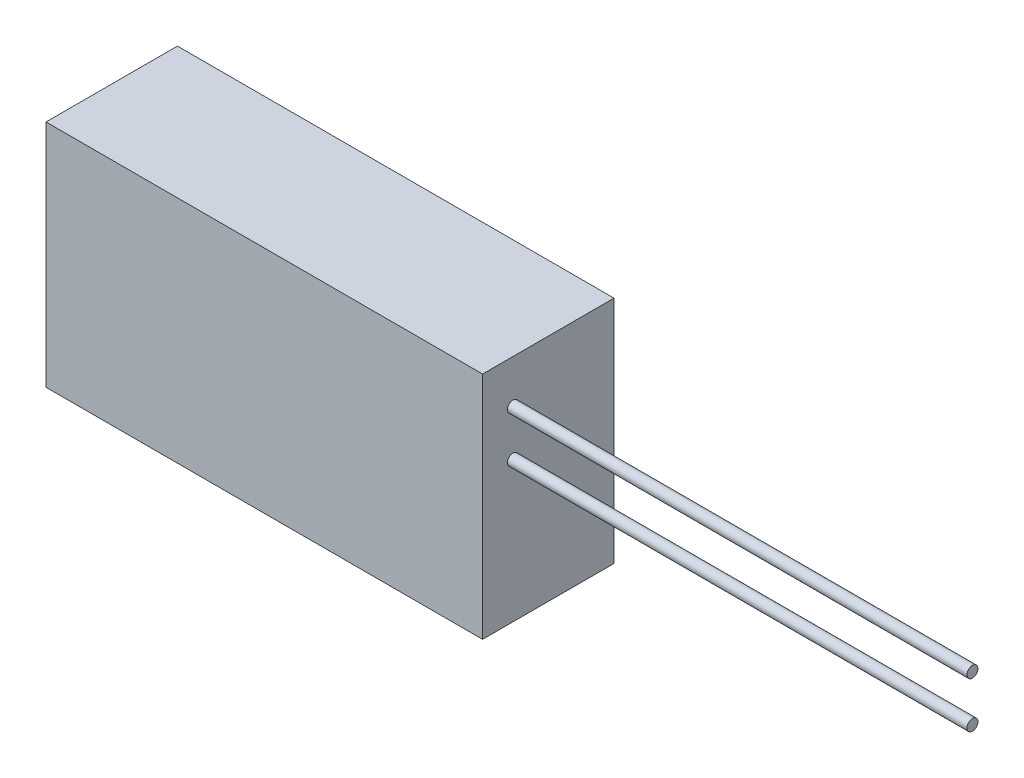
from build123d import *

# Parameters (mm, degrees)
SKETCH_1_W      = 47.5
SKETCH_1_H      = 25
EXTRUDE_1_DEPTH = 7.15
SKETCH_2_R      = 0.6
EXTRUDE_2_DEPTH = 50


with BuildPart() as part:
    # 草圖1 → 填料-伸長1 (new body, symmetric)
    with BuildSketch(Plane.XY):
        Rectangle(SKETCH_1_W, SKETCH_1_H)
    extrude(amount=EXTRUDE_1_DEPTH, both=True)

    # 草圖2 → 填料-伸長2 (add)
    with BuildSketch(Plane(origin=(23.75, 0, 0), x_dir=(0, 0, -1), z_dir=(1, 0, 0))):
        with Locations((-3.85, 2.8)):
            Circle(SKETCH_2_R)
        with Locations((-3.85, 7.8)):
            Circle(SKETCH_2_R)
    extrude(amount=EXTRUDE_2_DEPTH)


solid = part.part
